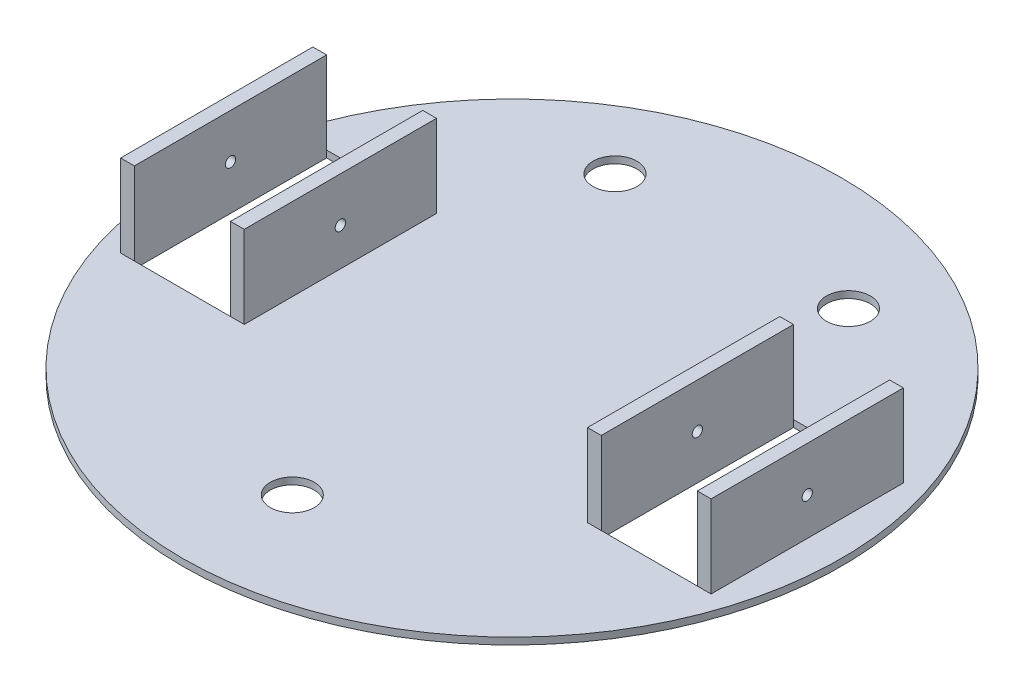
from build123d import *

# Parameters (mm, degrees)
SKETCH1_R           = 152.4
BOSS_EXTRUDE1_DEPTH = 3.175
SKETCH2_W           = 44.45
SKETCH2_H           = 88.9
CUT_EXTRUDE1_DEPTH  = 4.175
SKETCH3_W           = 6.35
SKETCH3_H           = 88.9
BOSS_EXTRUDE2_DEPTH = 38.1
SKETCH4_R           = 2.38125
CUT_EXTRUDE2_DEPTH  = 289.925
SKETCH5_R           = 10.16
CUT_EXTRUDE3_DEPTH  = 4.175


with BuildPart() as part:
    # Sketch1 → Boss-Extrude1 (new body)
    with BuildSketch(Plane(origin=(0, 0, 0), x_dir=(1, 0, 0), z_dir=(0, 1, 0))):
        Circle(SKETCH1_R)
    extrude(amount=BOSS_EXTRUDE1_DEPTH)

    # Sketch2 → Cut-Extrude1 (cut, through all)
    with BuildSketch(Plane(origin=(0, 3.175, 0), x_dir=(1, 0, 0), z_dir=(0, 1, 0))):
        with Locations((-107.95, 0)):
            Rectangle(SKETCH2_W, SKETCH2_H)
    cut_extrude1 = extrude(amount=-CUT_EXTRUDE1_DEPTH, mode=Mode.SUBTRACT)

    # Sketch3 → Boss-Extrude2 (add)
    with BuildSketch(Plane(origin=(0, 3.175, 0), x_dir=(1, 0, 0), z_dir=(0, 1, 0))):
        with Locations((-133.35, 0)):
            Rectangle(SKETCH3_W, SKETCH3_H)
        with Locations((-82.55, 0)):
            Rectangle(SKETCH3_W, SKETCH3_H)
    boss_extrude2 = extrude(amount=BOSS_EXTRUDE2_DEPTH)

    # Mirror1: Cut-Extrude1, Boss-Extrude2 across plane
    add(cut_extrude1.mirror(Plane(origin=(0, 0, 0), x_dir=(0, 0, 1), z_dir=(1, 0, 0))), mode=Mode.SUBTRACT)
    add(boss_extrude2.mirror(Plane(origin=(0, 0, 0), x_dir=(0, 0, 1), z_dir=(1, 0, 0))))

    # Sketch4 → Cut-Extrude2 (cut, through all)
    with BuildSketch(Plane(origin=(136.525, 0, 0), x_dir=(0, 0, -1), z_dir=(1, 0, 0))):
        with Locations((0, 20.6375)):
            Circle(SKETCH4_R)
    extrude(amount=-CUT_EXTRUDE2_DEPTH, mode=Mode.SUBTRACT)

    # Sketch5 → Cut-Extrude3 (cut, through all)
    with BuildSketch(Plane(origin=(0, 3.175, 0), x_dir=(1, 0, 0), z_dir=(0, 1, 0))):
        with Locations((0, -101.6)):
            Circle(SKETCH5_R)
        with Locations((-53.975, 101.6)):
            Circle(SKETCH5_R)
        with Locations((53.975, 101.6)):
            Circle(SKETCH5_R)
    extrude(amount=-CUT_EXTRUDE3_DEPTH, mode=Mode.SUBTRACT)


solid = part.part
